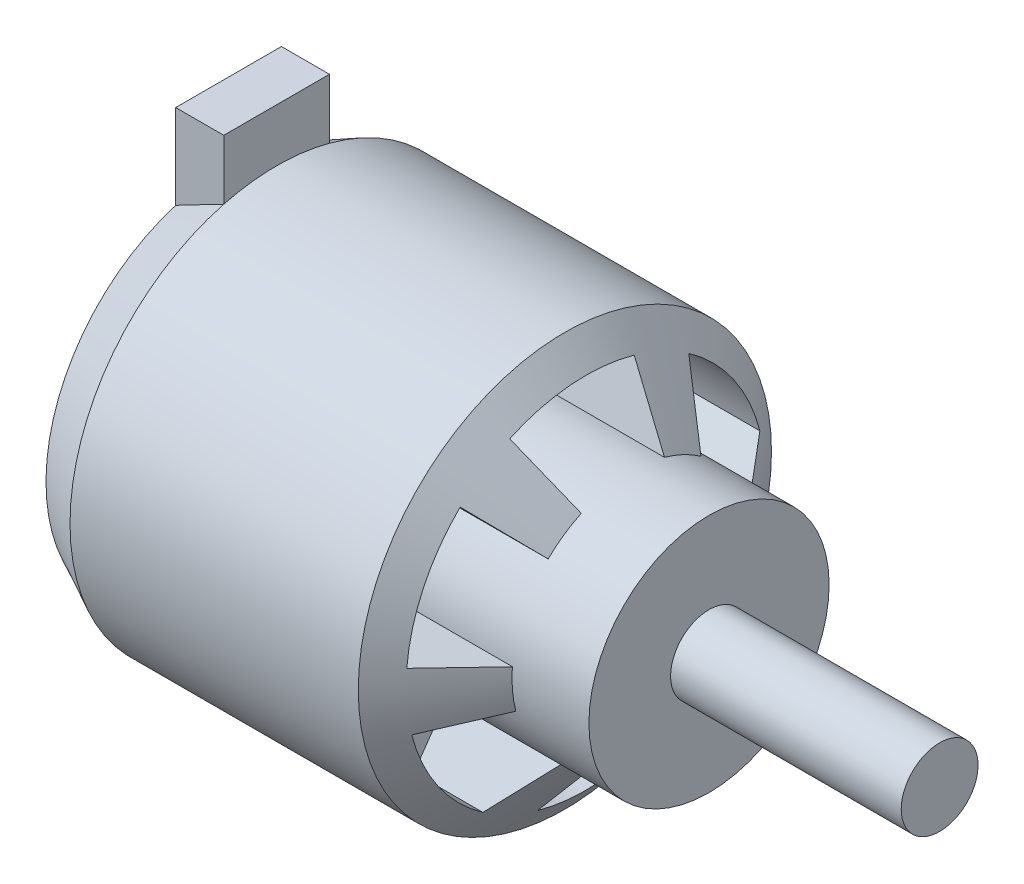
from build123d import *

# Parameters (mm, degrees)
CUT_EXTRUDE1_DEPTH  = 20
SKETCH3_W           = 5
SKETCH3_H           = 11
BOSS_EXTRUDE1_DEPTH = 27
SKETCH4_R           = 1.5
CUT_EXTRUDE2_DEPTH  = 5


with BuildPart() as part:
    # Sketch1 → Revolve1 (revolve)
    with BuildSketch(Plane.XY):
        Polygon((0, 0), (0, 19), (5, 21.5), (35, 21.5), (42, 12.5), (50, 12.5), (50, 4), (74, 4), (74, 0), align=None)
    revolve(axis=Axis((0, 0, 0), (1, 0, 0)))

    # Sketch2 → Cut-Extrude1 (cut)
    with BuildSketch(Plane(origin=(50, 0, 0), x_dir=(0, 0, -1), z_dir=(1, 0, 0))):
        with BuildLine():
            Line((18.630423, -1.611622), (12.453492, -1.077288))
            ThreePointArc((12.453492, -1.077288), (11.3025, -5.338867), (8.741979, -8.93464))
            Line((8.741979, -8.93464), (13.078001, -13.366222))
            ThreePointArc((13.078001, -13.366222), (16.908539, -7.986946), (18.630423, -1.611622))
        make_face()
        with BuildLine():
            Line((7.919506, -16.940231), (5.293787, -11.323684))
            ThreePointArc((5.293787, -11.323684), (1.027655, -12.457685), (-3.366636, -12.038096))
            Line((-3.366636, -12.038096), (-5.036487, -18.008992))
            ThreePointArc((-5.036487, -18.008992), (1.537372, -18.636697), (7.919506, -16.940231))
        make_face()
        with BuildLine():
            Line((-10.710917, -15.328609), (-7.159704, -10.246396))
            ThreePointArc((-7.159704, -10.246396), (-10.274845, -7.118818), (-12.108615, -3.103456))
            Line((-12.108615, -3.103456), (-18.114488, -4.64277))
            ThreePointArc((-18.114488, -4.64277), (-15.371167, -10.649752), (-10.710917, -15.328609))
        make_face()
        with BuildLine():
            Line((-18.630423, 1.611622), (-12.453492, 1.077288))
            ThreePointArc((-12.453492, 1.077288), (-11.3025, 5.338867), (-8.741979, 8.93464))
            Line((-8.741979, 8.93464), (-13.078001, 13.366222))
            ThreePointArc((-13.078001, 13.366222), (-16.908539, 7.986946), (-18.630423, 1.611622))
        make_face()
        with BuildLine():
            Line((-7.919506, 16.940231), (-5.293787, 11.323684))
            ThreePointArc((-5.293787, 11.323684), (-1.027655, 12.457685), (3.366636, 12.038096))
            Line((3.366636, 12.038096), (5.036487, 18.008992))
            ThreePointArc((5.036487, 18.008992), (-1.537372, 18.636697), (-7.919506, 16.940231))
        make_face()
        with BuildLine():
            Line((10.710917, 15.328609), (7.159704, 10.246396))
            ThreePointArc((7.159704, 10.246396), (10.274845, 7.118818), (12.108615, 3.103456))
            Line((12.108615, 3.103456), (18.114488, 4.64277))
            ThreePointArc((18.114488, 4.64277), (15.371167, 10.649752), (10.710917, 15.328609))
        make_face()
    extrude(amount=-CUT_EXTRUDE1_DEPTH, mode=Mode.SUBTRACT)

    # Sketch3 → Boss-Extrude1 (add)
    with BuildSketch(Plane(origin=(0, 0, 0), x_dir=(1, 0, 0), z_dir=(0, 1, 0))):
        with Locations((2.5, 0)):
            Rectangle(SKETCH3_W, SKETCH3_H)
    extrude(amount=BOSS_EXTRUDE1_DEPTH)

    # Sketch4 → Cut-Extrude2 (cut)
    with BuildSketch(Plane.ZY):
        with Locations((0, 12.35)):
            Circle(SKETCH4_R)
        with Locations((12.35, 0)):
            Circle(SKETCH4_R)
        with Locations((0, -12.35)):
            Circle(SKETCH4_R)
        with Locations((-12.35, 0)):
            Circle(SKETCH4_R)
    extrude(amount=-CUT_EXTRUDE2_DEPTH, mode=Mode.SUBTRACT)


solid = part.part
